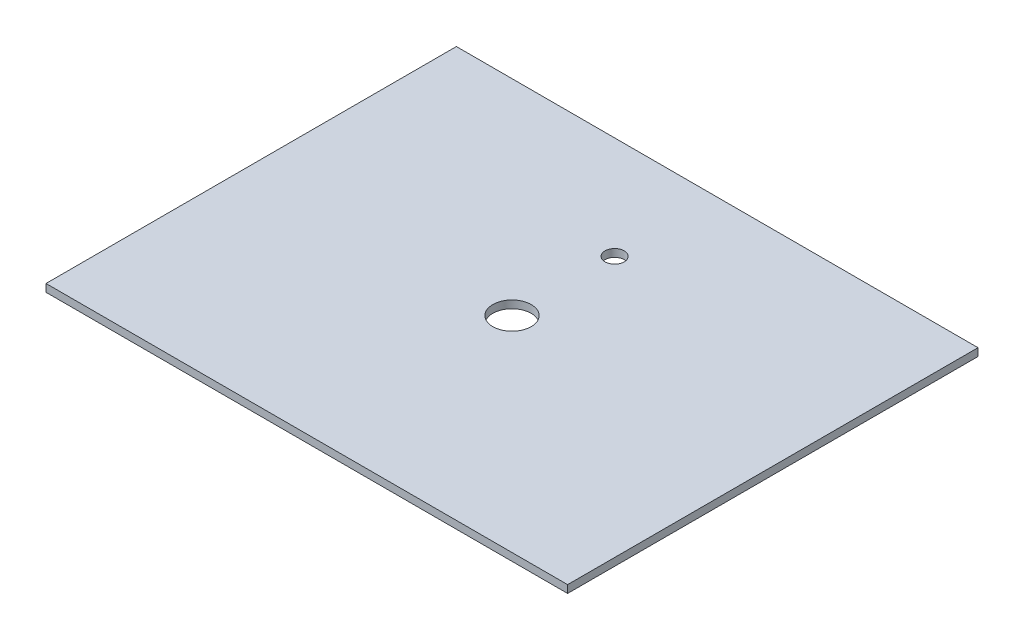
from build123d import *

# Parameters (mm, degrees)
SKETCH1_W           = 680
SKETCH1_H           = 535
SKETCH1_R           = 25
SKETCH1_R_2         = 12.5
BOSS_EXTRUDE1_DEPTH = 10


with BuildPart() as part:
    # Sketch1 → Boss-Extrude1 (new body)
    with BuildSketch(Plane(origin=(0, 0, 0), x_dir=(1, 0, 0), z_dir=(0, 1, 0))):
        Rectangle(SKETCH1_W, SKETCH1_H)
        Circle(SKETCH1_R, mode=Mode.SUBTRACT)
        with Locations((0, 133.75)):
            Circle(SKETCH1_R_2, mode=Mode.SUBTRACT)
    extrude(amount=BOSS_EXTRUDE1_DEPTH)


solid = part.part
